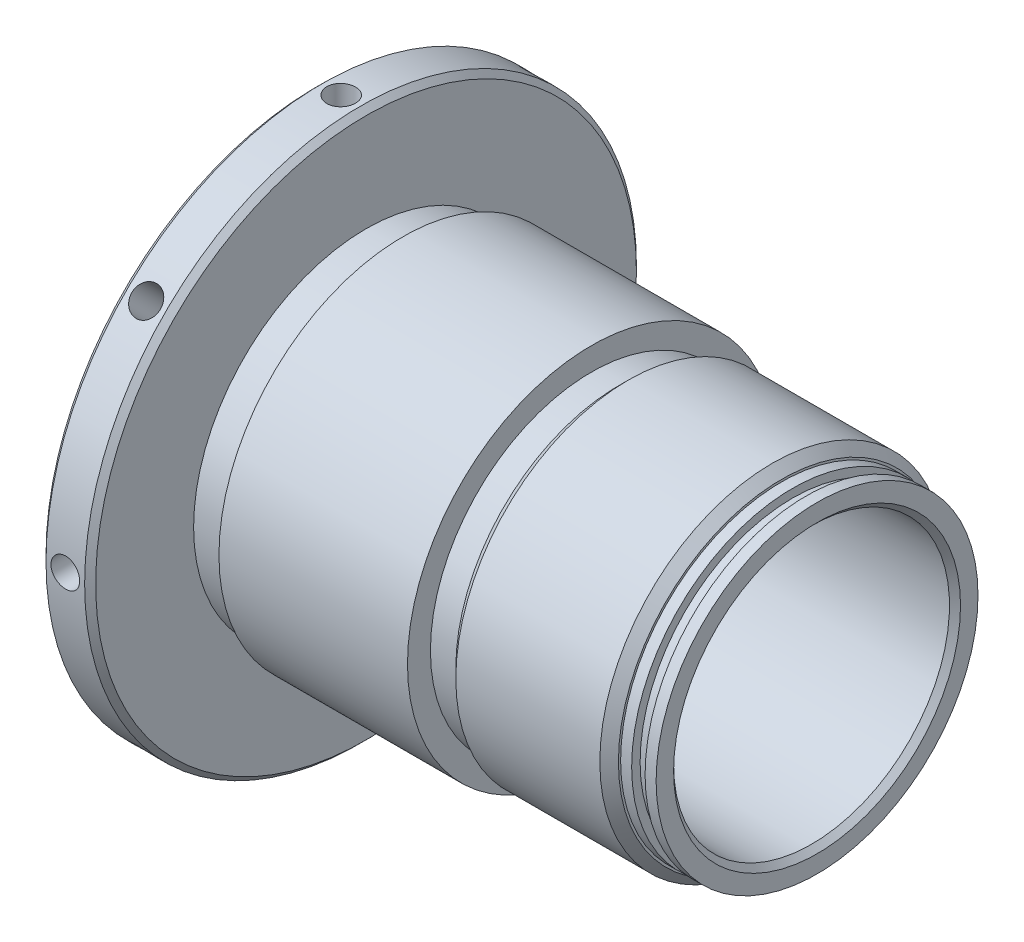
from build123d import *

# Parameters (mm, degrees)
CHAMFER1_SIZE      = 0.762
SKETCH3_W          = 6.858
SKETCH3_H          = 18.542
SKETCH5_W          = 5.08
SKETCH5_H          = 1.58115
CHAMFER3_SIZE      = 0.762
SKETCH6_R          = 1.9812
CUT_EXTRUDE2_DEPTH = 6.35
CHAMFER4_SIZE      = 1.2827
CIRPATTERN2_COUNT  = 8
SKETCH7_W          = 1.524
SKETCH7_H          = 0.4064
EXTRUDE1_DEPTH     = 0.0254


with BuildPart() as part:
    # Sketch1 → Revolve1 (revolve)
    with BuildSketch(Plane.XY, mode=Mode.PRIVATE) as revolve1_sk:
        Polygon((0, 19.558), (0, 25.39365), (62.2808, 25.39365), (62.2808, 19.05), (22.098, 19.05), (20.828, 20.32), (17.78, 20.32), (17.018, 19.558), align=None)
    revolve(revolve1_sk.sketch.rotate(Axis((0, 0, 0), (1, 0, 0)), 90), axis=Axis((0, 0, 0), (1, 0, 0)))  # turned: the seam where the file's is

    # Sketch2 → Cut-Revolve1 (revolve, cut)
    with BuildSketch(Plane.XY, mode=Mode.PRIVATE) as cut_revolve1_sk:
        Polygon((31.115, 25.39365), (62.2808, 25.39365), (62.2808, 22.225), (60.7568, 22.225), (60.7568, 21.0566), (58.9026, 21.0566), (58.9026, 22.225), (57.3786, 22.225), (57.3786, 23.8125), (34.925, 23.8125), (34.925, 22.225), (31.115, 22.225), align=None)
    revolve(cut_revolve1_sk.sketch.rotate(Axis((0, 0, 0), (1, 0, 0)), 90), axis=Axis((0, 0, 0), (1, 0, 0)), mode=Mode.SUBTRACT)  # turned: the seam where the file's is

    # Chamfer1
    chamfer1_edges = [part.edges().sort_by_distance(p)[0] for p in [
        (62.2808, 0, -19.05),
    ]]
    chamfer(chamfer1_edges, length=CHAMFER1_SIZE)

    # Sketch3 → Revolve2 (revolve)
    with BuildSketch(Plane.XY, mode=Mode.PRIVATE) as revolve2_sk:
        with Locations((-3.429, 28.829)):
            Rectangle(SKETCH3_W, SKETCH3_H)
    revolve(revolve2_sk.sketch.rotate(Axis((0, 0, 0), (-1, 0, 0)), 270), axis=Axis((0, 0, 0), (-1, 0, 0)))  # turned: the seam where the file's is

    # Sketch5 → Cut-Revolve2 (revolve, cut)
    with BuildSketch(Plane.XY, mode=Mode.PRIVATE) as cut_revolve2_sk:
        with Locations((2.54, 24.603075)):
            Rectangle(SKETCH5_W, SKETCH5_H)
    revolve(cut_revolve2_sk.sketch.rotate(Axis((23.353313309, 0, 0), (1, 0, 0)), 90), axis=Axis((23.353313309, 0, 0), (1, 0, 0)), mode=Mode.SUBTRACT)  # turned: the seam where the file's is

    # Chamfer3
    chamfer3_edges = [part.edges().sort_by_distance(p)[0] for p in [
        (0, 0, -38.1),
        (-6.858, 0, -38.1),
    ]]
    chamfer(chamfer3_edges, length=CHAMFER3_SIZE)

    # Sketch6 → Cut-Extrude2 (cut)
    with BuildSketch(Plane(origin=(-3.429, 38.1, 0), x_dir=(0, 0, 1), z_dir=(0, 1, 0))):
        Circle(SKETCH6_R)
    cut_extrude2 = extrude(amount=-CUT_EXTRUDE2_DEPTH, mode=Mode.SUBTRACT)

    # Chamfer4
    chamfer4_edges = [part.edges().sort_by_distance(p)[0] for p in [
        (34.925, 0, -23.8125),
        (57.3786, 0, -23.8125),
    ]]
    chamfer(chamfer4_edges, length=CHAMFER4_SIZE)

    # CirPattern2: Cut-Extrude2 ×8 about axis
    cirpattern2_axis = Axis((0, 0, 0), (1, 0, 0))
    for i in range(1, CIRPATTERN2_COUNT):
        add(cut_extrude2.rotate(cirpattern2_axis, i * 360 / CIRPATTERN2_COUNT), mode=Mode.SUBTRACT)

    # Sketch7 → Extrude1 (cut)
    with BuildSketch(Plane.ZY.offset(6.858)):
        with BuildLine():
            Line((-9.4996, 27.070692568), (-9.1646375, 27.271511318))
            add(Edge.make_bspline(
                [(-9.1646375, 27.271511318), (-9.13348371, 27.21936117), (-9.073794252, 27.119443498), (-8.974223262, 26.984429767), (-8.871050391, 26.869676221), (-8.76351161, 26.77585043), (-8.652263326, 26.701981233), (-8.536579299, 26.649675027), (-8.416849371, 26.617052049), (-8.335366779, 26.613089551), (-8.2946875, 26.611111318)],
                knots=[0, 0, 0, 0, 1.272034388, 2.437168799, 3.508375237, 4.49857839, 5.41946034, 6.295179144, 7.148887113, 8, 8, 8, 8], degree=3))
            add(Edge.make_bspline(
                [(-8.2946875, 26.611111318), (-8.259946467, 26.612078905), (-8.191072287, 26.613997148), (-8.089677592, 26.632428877), (-7.991204251, 26.660745465), (-7.897681832, 26.701298854), (-7.810400786, 26.750362973), (-7.73386228, 26.809624828), (-7.667694601, 26.875973751), (-7.613569219, 26.949994388), (-7.572043227, 27.029601436), (-7.540126584, 27.111312862), (-7.522414572, 27.196412272), (-7.519746458, 27.2537091), (-7.5184, 27.282623818)],
                knots=[0, 0, 0, 0, 1.095163259, 2.171163733, 3.241058638, 4.321873601, 5.38011039, 6.391990106, 7.366004449, 8.327778327, 9.272591725, 10.192022065, 11.087607919, 12, 12, 12, 12], degree=3))
            add(Edge.make_bspline(
                [(-7.5184, 27.282623818), (-7.520069088, 27.31561459), (-7.523462101, 27.382680009), (-7.552140231, 27.481626405), (-7.597254133, 27.579545879), (-7.638873647, 27.640115426), (-7.66048125, 27.671561318)],
                knots=[0, 0, 0, 0, 0.938893495, 1.908633276, 2.914225137, 4, 4, 4, 4], degree=3))
            add(Edge.make_bspline(
                [(-7.66048125, 27.671561318), (-7.678222176, 27.694256613), (-7.715467032, 27.741902547), (-7.7794966, 27.812824113), (-7.854630626, 27.885979548), (-7.938297896, 27.964162293), (-8.033546168, 28.043736112), (-8.137392197, 28.128495559), (-8.252487304, 28.215217299), (-8.333206483, 28.273376914), (-8.37485625, 28.303386318)],
                knots=[0, 0, 0, 0, 0.722233717, 1.516239348, 2.393582979, 3.351407094, 4.387010283, 5.505090956, 6.712668013, 8, 8, 8, 8], degree=3))
            add(Edge.make_bspline(
                [(-8.37485625, 28.303386318), (-8.416545222, 28.333080077), (-8.496251362, 28.389852282), (-8.60771773, 28.474109077), (-8.707394124, 28.551142514), (-8.794837518, 28.621677776), (-8.87000945, 28.68572443), (-8.933502281, 28.742667446), (-8.983698595, 28.794046823), (-9.01161153, 28.827377787), (-9.02414375, 28.842342568)],
                knots=[0, 0, 0, 0, 1.452282411, 2.77665338, 3.964542531, 5.026858415, 5.96415736, 6.766646006, 7.446254459, 8, 8, 8, 8], degree=3))
            add(Edge.make_bspline(
                [(-9.02414375, 28.842342568), (-9.041660439, 28.865665296), (-9.07610936, 28.911532571), (-9.121581869, 28.983223547), (-9.160231303, 29.056610892), (-9.190529321, 29.13189181), (-9.216042897, 29.208009434), (-9.233203406, 29.285956913), (-9.243948753, 29.365384487), (-9.245049152, 29.418835565), (-9.2456, 29.445592568)],
                knots=[0, 0, 0, 0, 1.068054152, 2.10047183, 3.106115577, 4.101338837, 5.06977816, 6.043150881, 7.020423561, 8, 8, 8, 8], degree=3))
            add(Edge.make_bspline(
                [(-9.2456, 29.445592568), (-9.244122354, 29.487514505), (-9.241198646, 29.570462326), (-9.216472685, 29.691633459), (-9.177445429, 29.807320161), (-9.122770097, 29.916377108), (-9.052287658, 30.015964652), (-8.970723382, 30.107228332), (-8.873574972, 30.183950112), (-8.766983442, 30.250984929), (-8.650311851, 30.303453813), (-8.528053807, 30.343033639), (-8.400014996, 30.365459982), (-8.313291493, 30.368678317), (-8.2692875, 30.370311318)],
                knots=[0, 0, 0, 0, 1.005424448, 1.989358655, 2.955360095, 3.929531133, 4.905563448, 5.876582895, 6.856512386, 7.866279853, 8.892233794, 9.918561126, 10.94386622, 12, 12, 12, 12], degree=3))
            add(Edge.make_bspline(
                [(-8.2692875, 30.370311318), (-8.222594465, 30.368700827), (-8.129736921, 30.365498075), (-7.99314822, 30.337650858), (-7.861641014, 30.291573046), (-7.755852559, 30.239282206), (-7.673057915, 30.187056172), (-7.609916807, 30.139484928), (-7.545932594, 30.084718777), (-7.48058916, 30.022611841), (-7.414993711, 29.95259425), (-7.348172418, 29.875145532), (-7.27996902, 29.79073899), (-7.236092958, 29.730482772), (-7.2136, 29.699592568)],
                knots=[0, 0, 0, 0, 1.286793592, 2.559021753, 3.825965368, 5.121522368, 5.803751409, 6.523245864, 7.299691795, 8.125521123, 9.008227632, 9.944561021, 10.946284179, 12, 12, 12, 12], degree=3))
            Line((-7.2136, 29.699592568), (-7.53506875, 29.455911318))
            add(Edge.make_bspline(
                [(-7.53506875, 29.455911318), (-7.554479905, 29.48091824), (-7.591861251, 29.529075725), (-7.64861356, 29.596517262), (-7.702104429, 29.658122936), (-7.754804801, 29.711632463), (-7.803931352, 29.759976158), (-7.851612657, 29.801365981), (-7.897162541, 29.836207472), (-7.95457988, 29.873390136), (-8.026715619, 29.910247818), (-8.117267255, 29.941436523), (-8.211896471, 29.960178745), (-8.27634732, 29.962656816), (-8.308975, 29.963911318)],
                knots=[0, 0, 0, 0, 1.181633172, 2.275549214, 3.290209073, 4.226197932, 5.078386478, 5.862611352, 6.581680152, 7.217281963, 8.414376989, 9.595101626, 10.782541182, 12, 12, 12, 12], degree=3))
            add(Edge.make_bspline(
                [(-8.308975, 29.963911318), (-8.349908316, 29.962539535), (-8.428844359, 29.959894181), (-8.540912619, 29.931002641), (-8.641777124, 29.885512183), (-8.728443377, 29.821757192), (-8.800600919, 29.746221403), (-8.852797568, 29.659298964), (-8.884213925, 29.563315595), (-8.888047581, 29.496360481), (-8.89, 29.462261318)],
                knots=[0, 0, 0, 0, 1.14458467, 2.207223713, 3.21896685, 4.227309161, 5.202851033, 6.127160689, 7.046193047, 8, 8, 8, 8], degree=3))
            add(Edge.make_bspline(
                [(-8.89, 29.462261318), (-8.889554936, 29.441032501), (-8.888664079, 29.398540155), (-8.876239354, 29.335762808), (-8.860277302, 29.27314405), (-8.83498289, 29.210965409), (-8.800062481, 29.148139453), (-8.754205993, 29.083584329), (-8.696453093, 29.016731046), (-8.652213449, 28.97324951), (-8.62885625, 28.950292568)],
                knots=[0, 0, 0, 0, 0.858281714, 1.717966888, 2.583508476, 3.4729293, 4.427298488, 5.488583878, 6.674047936, 8, 8, 8, 8], degree=3))
            add(Edge.make_bspline(
                [(-8.62885625, 28.950292568), (-8.620182701, 28.942552273), (-8.599576333, 28.924163105), (-8.561904183, 28.894057604), (-8.512155913, 28.856921117), (-8.451630591, 28.810971637), (-8.379212227, 28.757670041), (-8.294892858, 28.697697858), (-8.199612384, 28.629108194), (-8.13200035, 28.581154617), (-8.09625, 28.555798818)],
                knots=[0, 0, 0, 0, 0.420754252, 0.999615792, 1.744751191, 2.668019286, 3.750313428, 4.999500688, 6.413464383, 8, 8, 8, 8], degree=3))
            add(Edge.make_bspline(
                [(-8.09625, 28.555798818), (-8.053245605, 28.52450564), (-7.969973554, 28.463910738), (-7.851489213, 28.372870998), (-7.744058577, 28.283832735), (-7.647304463, 28.197364555), (-7.560271017, 28.114122351), (-7.48392381, 28.033104652), (-7.417484913, 27.954891888), (-7.345958817, 27.85461761), (-7.272871987, 27.731464991), (-7.210105865, 27.580578793), (-7.17052902, 27.429106067), (-7.165353542, 27.327298611), (-7.1628, 27.277067568)],
                knots=[0, 0, 0, 0, 1.163667725, 2.253281268, 3.268753668, 4.215851969, 5.092017293, 5.902905408, 6.650798638, 7.335211899, 8.59617414, 9.77448103, 10.901945474, 12, 12, 12, 12], degree=3))
            add(Edge.make_bspline(
                [(-7.1628, 27.277067568), (-7.163543955, 27.241543673), (-7.165017419, 27.171185732), (-7.181954883, 27.067874556), (-7.20677045, 26.967534282), (-7.244172374, 26.871405199), (-7.289822798, 26.777728671), (-7.347748838, 26.688961967), (-7.414891915, 26.60314046), (-7.491913912, 26.522552612), (-7.576195182, 26.44857325), (-7.665274116, 26.382764509), (-7.759296517, 26.327892828), (-7.857752326, 26.283116755), (-7.96066416, 26.248096478), (-8.067997407, 26.222722548), (-8.179928993, 26.207149512), (-8.256007618, 26.205533122), (-8.2946875, 26.204711318)],
                knots=[0, 0, 0, 0, 0.983748083, 1.948392443, 2.894712957, 3.844097841, 4.80183111, 5.778335162, 6.776009319, 7.81870978, 8.863265674, 9.881300176, 10.883814829, 11.87499822, 12.874611388, 13.892143829, 14.928324115, 16, 16, 16, 16], degree=3))
            add(Edge.make_bspline(
                [(-8.2946875, 26.204711318), (-8.324615329, 26.205290034), (-8.384094078, 26.206440178), (-8.472070093, 26.216608014), (-8.558268809, 26.230993907), (-8.64160859, 26.25383326), (-8.723163172, 26.281543995), (-8.802577859, 26.315664032), (-8.879891136, 26.356552832), (-8.955536277, 26.403303519), (-9.029320891, 26.457710378), (-9.100552919, 26.521078773), (-9.171569526, 26.59166101), (-9.240274595, 26.671373815), (-9.308057837, 26.758929363), (-9.373582811, 26.855146832), (-9.438205839, 26.959502131), (-9.478753042, 27.032936821), (-9.4996, 27.070692568)],
                knots=[0, 0, 0, 0, 0.915332311, 1.819136955, 2.706846663, 3.586547465, 4.459518054, 5.340707479, 6.227863349, 7.133153174, 8.059268498, 9.028702269, 10.047606654, 11.120612155, 12.245963614, 13.433783089, 14.680604001, 16, 16, 16, 16], degree=3))
        make_face()
        Polygon((-6.8072, 29.862311318), (-6.8072, 30.268711318), (-4.7244, 30.268711318), (-4.7244, 29.862311318), (-5.588, 29.862311318), (-5.588, 26.306311318), (-5.9436, 26.306311318), (-5.9436, 29.862311318), align=None)
        with BuildLine():
            Line((-0.4064, 29.592436318), (-0.7112, 29.303511318))
            add(Edge.make_bspline(
                [(-0.7112, 29.303511318), (-0.766355349, 29.355397093), (-0.875350837, 29.457931396), (-1.05304777, 29.590967273), (-1.238446919, 29.704932803), (-1.430580862, 29.797660023), (-1.62469154, 29.871646817), (-1.818202449, 29.924321989), (-2.009128657, 29.957914693), (-2.136114767, 29.961931852), (-2.1986875, 29.963911318)],
                knots=[0, 0, 0, 0, 1.08915593, 2.152340314, 3.188132944, 4.216796309, 5.218260357, 6.173443236, 7.099959455, 8, 8, 8, 8], degree=3))
            add(Edge.make_bspline(
                [(-2.1986875, 29.963911318), (-2.237082816, 29.963443069), (-2.313773869, 29.962507785), (-2.427689409, 29.950570528), (-2.540410221, 29.933402169), (-2.651723519, 29.908561456), (-2.761845731, 29.877078422), (-2.870393859, 29.837697302), (-2.977570388, 29.791784131), (-3.082365771, 29.738730455), (-3.183962277, 29.680449386), (-3.279916701, 29.615863918), (-3.370840648, 29.54704406), (-3.455025147, 29.472266803), (-3.532954446, 29.392209494), (-3.606483425, 29.308361367), (-3.673026042, 29.218431621), (-3.733131308, 29.124074847), (-3.786750073, 29.026948284), (-3.834082247, 28.92798679), (-3.873816162, 28.827518604), (-3.905254359, 28.725417658), (-3.931191837, 28.622473838), (-3.94943881, 28.517974345), (-3.959726018, 28.411807288), (-3.961505453, 28.340713614), (-3.9624, 28.304973818)],
                knots=[0, 0, 0, 0, 1.02818874, 2.053710826, 3.065248034, 4.081641283, 5.106893873, 6.131558223, 7.173050175, 8.228653731, 9.27666206, 10.308777013, 11.325269123, 12.329503258, 13.32196095, 14.316845687, 15.314881793, 16.315733098, 17.311955233, 18.285320748, 19.252783886, 20.203351036, 21.145449891, 22.095197417, 23.042428769, 24, 24, 24, 24], degree=3))
            add(Edge.make_bspline(
                [(-3.9624, 28.304973818), (-3.961544441, 28.268439565), (-3.959835658, 28.195470821), (-3.948899072, 28.086568138), (-3.928602255, 27.979282872), (-3.901468069, 27.873262482), (-3.86752636, 27.768325397), (-3.825216231, 27.664926557), (-3.775102512, 27.563069792), (-3.717096879, 27.463672856), (-3.653487676, 27.366851019), (-3.582228915, 27.275648434), (-3.506535093, 27.188850616), (-3.423648591, 27.108384728), (-3.336227244, 27.032098457), (-3.241659161, 26.962093579), (-3.141803896, 26.897021661), (-3.036509102, 26.837702813), (-2.926917289, 26.784710201), (-2.814547301, 26.737587194), (-2.699040154, 26.698779066), (-2.581002873, 26.66714994), (-2.460576173, 26.641224186), (-2.337148768, 26.624545335), (-2.211628191, 26.612442092), (-2.127015518, 26.611557152), (-2.0843875, 26.611111318)],
                knots=[0, 0, 0, 0, 0.93586088, 1.869166235, 2.799637598, 3.729985548, 4.670839027, 5.622275134, 6.589130586, 7.576015415, 8.568469353, 9.55398029, 10.53834874, 11.515998671, 12.510579167, 13.508179873, 14.527009472, 15.561807829, 16.601455013, 17.643573243, 18.680854198, 19.719860599, 20.772568776, 21.833555941, 22.908541556, 24, 24, 24, 24], degree=3))
            add(Edge.make_bspline(
                [(-2.0843875, 26.611111318), (-2.033014025, 26.612185215), (-1.93213386, 26.614293986), (-1.783842237, 26.63070997), (-1.641418783, 26.656348729), (-1.505263696, 26.693896315), (-1.375218837, 26.741788909), (-1.250807468, 26.799521515), (-1.133009099, 26.869308503), (-1.021469607, 26.948074071), (-0.918722101, 27.035829721), (-0.826053877, 27.130524803), (-0.744942996, 27.231699668), (-0.674180533, 27.338758413), (-0.615640426, 27.452587189), (-0.567590332, 27.572628167), (-0.530758928, 27.698935342), (-0.51563957, 27.786211879), (-0.508, 27.830311318)],
                knots=[0, 0, 0, 0, 1.13008108, 2.219097802, 3.278683437, 4.311054135, 5.322181354, 6.324827112, 7.324222904, 8.330512327, 9.32562643, 10.293043162, 11.24128371, 12.174520618, 13.111833804, 14.052305215, 15.015860969, 16, 16, 16, 16], degree=3))
            Line((-0.508, 27.830311318), (-1.8288, 27.830311318))
            Line((-1.8288, 27.830311318), (-1.8288, 28.236711318))
            Line((-1.8288, 28.236711318), (-0.1524, 28.236711318))
            add(Edge.make_bspline(
                [(-0.1524, 28.236711318), (-0.154331215, 28.160964394), (-0.158110953, 28.012713981), (-0.184623842, 27.796513809), (-0.227436455, 27.592312439), (-0.285921832, 27.399894817), (-0.361632293, 27.219533623), (-0.453755294, 27.051045734), (-0.563765241, 26.895519631), (-0.687743576, 26.751685639), (-0.826880374, 26.623384019), (-0.977416048, 26.510618713), (-1.139599309, 26.415631364), (-1.313276743, 26.338352493), (-1.497879789, 26.278040242), (-1.693835617, 26.235278501), (-1.90087849, 26.209658796), (-2.042773932, 26.206385424), (-2.11534375, 26.204711318)],
                knots=[0, 0, 0, 0, 1.140356446, 2.231883559, 3.274166699, 4.278491846, 5.25512956, 6.21435461, 7.1637429, 8.11826594, 9.068280886, 10.0076534, 10.945064095, 11.891975133, 12.864533718, 13.863980011, 14.907571808, 16, 16, 16, 16], degree=3))
            add(Edge.make_bspline(
                [(-2.11534375, 26.204711318), (-2.160073739, 26.205355628), (-2.248295693, 26.206626416), (-2.378591776, 26.215657685), (-2.505295313, 26.229560701), (-2.628387846, 26.2505559), (-2.748322156, 26.276271484), (-2.864499254, 26.309200974), (-2.9773617, 26.34731779), (-3.087083936, 26.390672869), (-3.192670061, 26.440906655), (-3.294590367, 26.496730802), (-3.393408237, 26.557857458), (-3.48845055, 26.625343748), (-3.580212513, 26.698684896), (-3.668102444, 26.778027902), (-3.752612373, 26.863130201), (-3.805550562, 26.92356134), (-3.832225, 26.954011318)],
                knots=[0, 0, 0, 0, 1.107784379, 2.184907829, 3.233506516, 4.263428166, 5.276301166, 6.270063455, 7.25232949, 8.225834625, 9.190232166, 10.146266622, 11.1027726, 12.066435141, 13.031522626, 14.010570082, 14.99756817, 16, 16, 16, 16], degree=3))
            add(Edge.make_bspline(
                [(-3.832225, 26.954011318), (-3.870927382, 27.002319374), (-3.947689726, 27.098133622), (-4.046498574, 27.251648256), (-4.130729465, 27.410599208), (-4.199072739, 27.575428966), (-4.25243844, 27.745983356), (-4.290710982, 27.922044439), (-4.313135097, 28.103838933), (-4.316365627, 28.226860432), (-4.318, 28.289098818)],
                knots=[0, 0, 0, 0, 1.023165419, 2.029347347, 3.013907458, 3.994755782, 4.975994455, 5.96558838, 6.970761222, 8, 8, 8, 8], degree=3))
            add(Edge.make_bspline(
                [(-4.318, 28.289098818), (-4.317397446, 28.335703721), (-4.316199995, 28.428321206), (-4.301680045, 28.565824759), (-4.280847537, 28.700886777), (-4.25022718, 28.833396856), (-4.211626311, 28.963443494), (-4.163450902, 29.091087074), (-4.107360417, 29.216402923), (-4.042167055, 29.33852847), (-3.969616123, 29.455843148), (-3.890877325, 29.567874691), (-3.804832563, 29.672582883), (-3.712886996, 29.771293794), (-3.613943615, 29.862767323), (-3.508929346, 29.947850365), (-3.39776326, 30.026657051), (-3.280095626, 30.0979461), (-3.15768273, 30.161982583), (-3.030818001, 30.218123238), (-2.899540167, 30.264521035), (-2.764832744, 30.303888928), (-2.625676086, 30.333001406), (-2.483080023, 30.354113917), (-2.336301279, 30.368560374), (-2.237087278, 30.369722213), (-2.18678125, 30.370311318)],
                knots=[0, 0, 0, 0, 1.008945113, 2.00506715, 2.99143336, 3.967273523, 4.948097931, 5.927297278, 6.919902385, 7.919676788, 8.923139349, 9.905703106, 10.883022732, 11.856032218, 12.825136022, 13.798837087, 14.781400844, 15.773989409, 16.776158564, 17.77167057, 18.775803737, 19.789618931, 20.80898985, 21.851988756, 22.910860228, 24, 24, 24, 24], degree=3))
            add(Edge.make_bspline(
                [(-2.18678125, 30.370311318), (-2.145755417, 30.369655267), (-2.06440601, 30.368354395), (-1.943353861, 30.359337504), (-1.824172777, 30.345045827), (-1.706686044, 30.325543136), (-1.591293749, 30.298979557), (-1.477667168, 30.26719173), (-1.365641588, 30.23018085), (-1.255568098, 30.18604102), (-1.146706574, 30.13594086), (-1.038451722, 30.079546372), (-0.931173426, 30.015893241), (-0.824685645, 29.944792462), (-0.718316876, 29.867465187), (-0.613749545, 29.781699804), (-0.508459583, 29.690878476), (-0.440757095, 29.625575652), (-0.4064, 29.592436318)],
                knots=[0, 0, 0, 0, 0.985871117, 1.954866573, 2.915460327, 3.869826059, 4.81536089, 5.759505086, 6.70452669, 7.649098992, 8.607881297, 9.583363685, 10.581137262, 11.603961102, 12.659522466, 13.73993555, 14.853081303, 16, 16, 16, 16], degree=3))
        make_face()
        with BuildLine():
            add(Edge.make_bspline(
                [(1.8288, 28.285923818), (1.829171354, 28.349432472), (1.829892715, 28.472798948), (1.837917617, 28.65256131), (1.85124865, 28.821201381), (1.869518001, 28.978727234), (1.891750439, 29.125179535), (1.921429366, 29.260166907), (1.955180865, 29.384314114), (1.994298183, 29.498025992), (2.038436816, 29.602834532), (2.086477249, 29.700677738), (2.140326032, 29.791407564), (2.196905609, 29.87647213), (2.258506293, 29.954478987), (2.323375072, 30.026529755), (2.39404377, 30.090959228), (2.468110092, 30.149655168), (2.546244617, 30.201109164), (2.626220189, 30.246430799), (2.708587283, 30.285148957), (2.793570781, 30.315592004), (2.880406843, 30.340737221), (2.969399026, 30.357932846), (3.060694266, 30.368752358), (3.122316871, 30.369786735), (3.15356875, 30.370311318)],
                knots=[0, 0, 0, 0, 1.646270934, 3.197905019, 4.663502075, 6.030701355, 7.308322542, 8.50163776, 9.611534131, 10.641858119, 11.616356847, 12.558055219, 13.465016945, 14.349605745, 15.204443733, 16.039544428, 16.859896111, 17.680448484, 18.487036065, 19.28249412, 20.06191084, 20.843045899, 21.620316918, 22.403196591, 23.190181807, 24, 24, 24, 24], degree=3))
            add(Edge.make_bspline(
                [(3.15356875, 30.370311318), (3.185081693, 30.369759056), (3.247751021, 30.368660779), (3.340403679, 30.358105011), (3.430915856, 30.340589931), (3.518901671, 30.315772883), (3.605083856, 30.284984269), (3.688788319, 30.246393756), (3.770534988, 30.201472744), (3.849024797, 30.148689186), (3.925119423, 30.089839309), (3.996949768, 30.023313252), (4.064522371, 29.949782747), (4.128685294, 29.870034506), (4.187618179, 29.782538958), (4.24374097, 29.688817884), (4.293975186, 29.587232291), (4.342355722, 29.479477123), (4.384116006, 29.36257086), (4.421777198, 29.237172492), (4.452207262, 29.101800847), (4.477554477, 28.957166177), (4.497190882, 28.802737316), (4.511492476, 28.638845302), (4.519047171, 28.465382309), (4.520469901, 28.346784452), (4.5212, 28.285923818)],
                knots=[0, 0, 0, 0, 0.810914788, 1.612654377, 2.396697861, 3.181598691, 3.963628158, 4.749916497, 5.551656086, 6.361998678, 7.18212741, 8.025565596, 8.878627764, 9.750805457, 10.657531673, 11.591944965, 12.560506719, 13.57287815, 14.630710178, 15.753379473, 16.941251878, 18.199788006, 19.531962791, 20.947069417, 22.433333509, 24, 24, 24, 24], degree=3))
            add(Edge.make_bspline(
                [(4.5212, 28.285923818), (4.520462332, 28.225328637), (4.519025015, 28.107261399), (4.511577168, 27.934578902), (4.496906516, 27.77155666), (4.478554957, 27.617803696), (4.453137901, 27.47395995), (4.421885698, 27.339527664), (4.387186029, 27.213926295), (4.344352719, 27.098184805), (4.297471062, 26.990688603), (4.246463431, 26.890307258), (4.191816471, 26.79615351), (4.132280001, 26.708980996), (4.068821132, 26.628172199), (4.000081655, 26.555153519), (3.927999276, 26.488165556), (3.851680717, 26.428557896), (3.771966794, 26.37638463), (3.690500895, 26.329725842), (3.605837559, 26.292102633), (3.519895421, 26.259797705), (3.431445181, 26.235117102), (3.340597096, 26.218051775), (3.24781327, 26.206083234), (3.185092367, 26.205170207), (3.15356875, 26.204711318)],
                knots=[0, 0, 0, 0, 1.561518951, 3.042555995, 4.452378317, 5.7783523, 7.031515105, 8.214008947, 9.334062868, 10.386615937, 11.391082383, 12.354592575, 13.286541444, 14.194233754, 15.072674879, 15.931287219, 16.775624067, 17.606195743, 18.42308326, 19.229000347, 20.022332153, 20.807536673, 21.593273796, 22.3848459, 23.188221202, 24, 24, 24, 24], degree=3))
            add(Edge.make_bspline(
                [(3.15356875, 26.204711318), (3.122317738, 26.205239286), (3.060696843, 26.206280335), (2.96938908, 26.217050966), (2.880764407, 26.234367224), (2.794385498, 26.258613267), (2.709809185, 26.288291458), (2.628187949, 26.326957331), (2.548614258, 26.371487993), (2.471300412, 26.422201529), (2.397699216, 26.48030354), (2.327396497, 26.544567202), (2.26215839, 26.616596175), (2.201438464, 26.695253124), (2.143729971, 26.779814411), (2.090645841, 26.871434578), (2.041545078, 26.969750338), (1.996664116, 27.075396878), (1.956871812, 27.189915817), (1.921722258, 27.314617275), (1.89396943, 27.450601903), (1.870214326, 27.596777519), (1.851053991, 27.753772256), (1.837973174, 27.921671346), (1.829888389, 28.100370162), (1.829169417, 28.222943921), (1.8288, 28.285923818)],
                knots=[0, 0, 0, 0, 0.810891512, 1.598919785, 2.382837074, 3.152667961, 3.926044502, 4.706494248, 5.493654104, 6.291793342, 7.103789334, 7.925228297, 8.761435821, 9.622817696, 10.50288917, 11.416980706, 12.369136599, 13.353924996, 14.394355917, 15.514179734, 16.714354668, 17.994756427, 19.357759367, 20.818452758, 22.365282078, 24, 24, 24, 24], degree=3))
        make_face()
        with BuildLine():
            add(Edge.make_bspline(
                [(2.1844, 28.287511318), (2.184535228, 28.234586448), (2.184797678, 28.131869668), (2.191653989, 27.982608029), (2.200994195, 27.843391563), (2.213041359, 27.714043502), (2.230932103, 27.595001671), (2.250978211, 27.48544733), (2.275373111, 27.385960255), (2.304236385, 27.295857758), (2.337111961, 27.213610709), (2.373006622, 27.137078408), (2.411567253, 27.065356776), (2.454722488, 26.999090041), (2.501722284, 26.938062103), (2.551505039, 26.881192796), (2.605928699, 26.830477493), (2.681218536, 26.769652553), (2.780614179, 26.706798549), (2.905849176, 26.65206525), (3.034534853, 26.617668837), (3.121878886, 26.613294624), (3.165475, 26.611111318)],
                knots=[0, 0, 0, 0, 1.459021318, 2.831673884, 4.118529203, 5.306027144, 6.411944654, 7.436330062, 8.375795394, 9.233974572, 10.042671642, 10.816086306, 11.563610507, 12.285937304, 12.993564865, 13.685989202, 14.367179055, 15.041617293, 16.353048772, 17.594441528, 18.799311195, 20, 20, 20, 20], degree=3))
            add(Edge.make_bspline(
                [(3.165475, 26.611111318), (3.209353114, 26.612920189), (3.297018749, 26.616534195), (3.425099135, 26.651401885), (3.549439553, 26.704010715), (3.646882826, 26.766217571), (3.721016549, 26.82545922), (3.774131944, 26.875968101), (3.822883104, 26.932523852), (3.869121, 26.993544015), (3.911528955, 27.060194395), (3.95009232, 27.132154495), (3.985282222, 27.209624144), (4.005330886, 27.263704949), (4.01558125, 27.291355068)],
                knots=[0, 0, 0, 0, 1.353760809, 2.704726607, 4.075137775, 5.516104923, 6.260822281, 7.007110065, 7.778089737, 8.566572457, 9.372053459, 10.217411131, 11.088608312, 12, 12, 12, 12], degree=3))
            add(Edge.make_bspline(
                [(4.01558125, 27.291355068), (4.027527057, 27.326710702), (4.051782168, 27.398497802), (4.083041853, 27.509856698), (4.10766013, 27.626694021), (4.129808095, 27.748311531), (4.144925281, 27.875606122), (4.157093034, 28.008183933), (4.164260095, 28.146144922), (4.165148523, 28.239878314), (4.1656, 28.287511318)],
                knots=[0, 0, 0, 0, 0.884706709, 1.796334032, 2.740027952, 3.714592787, 4.726048262, 5.777819803, 6.87074269, 8, 8, 8, 8], degree=3))
            add(Edge.make_bspline(
                [(4.1656, 28.287511318), (4.164977123, 28.335136618), (4.163758642, 28.428301885), (4.159101138, 28.564742239), (4.147074037, 28.694332827), (4.133716086, 28.817631929), (4.114020444, 28.933957014), (4.092784463, 29.044281897), (4.06425381, 29.147239795), (4.033777549, 29.244442654), (3.99889666, 29.334786115), (3.960500172, 29.418691391), (3.919493002, 29.49656356), (3.874953089, 29.568188969), (3.827409177, 29.63388844), (3.775606401, 29.692344702), (3.721599599, 29.745369502), (3.645954909, 29.805895241), (3.546924016, 29.86760871), (3.423698303, 29.924402083), (3.295462989, 29.957016363), (3.208773088, 29.961614657), (3.165475, 29.963911318)],
                knots=[0, 0, 0, 0, 1.31362396, 2.569729283, 3.763502607, 4.902122613, 5.988968491, 7.01645872, 7.998833611, 8.933434873, 9.825090667, 10.667526885, 11.477055099, 12.250526234, 12.991942729, 13.710640831, 14.402115721, 15.076753259, 16.378508321, 17.609869233, 18.806226677, 20, 20, 20, 20], degree=3))
            add(Edge.make_bspline(
                [(3.165475, 29.963911318), (3.121650186, 29.961611488), (3.033920719, 29.957007639), (2.904352554, 29.924523597), (2.780154691, 29.867903204), (2.681385673, 29.805690838), (2.605688225, 29.746437888), (2.552385235, 29.695055235), (2.502406723, 29.638850001), (2.456366238, 29.577260816), (2.413244817, 29.511071338), (2.373642313, 29.439760858), (2.337961093, 29.362968001), (2.305034075, 29.280757897), (2.276082756, 29.190663173), (2.252201979, 29.091298642), (2.230140408, 28.982092756), (2.214522587, 28.862406191), (2.200638614, 28.733025732), (2.191716027, 28.593461719), (2.184774743, 28.443949748), (2.184527416, 28.340701878), (2.1844, 28.287511318)],
                knots=[0, 0, 0, 0, 1.207732386, 2.417664972, 3.655092373, 4.956220595, 5.625982001, 6.301752483, 6.994047911, 7.697131622, 8.419323945, 9.170223765, 9.943494443, 10.752040957, 11.610060368, 12.549350801, 13.567764191, 14.679664412, 15.874934091, 17.154273443, 18.533957287, 20, 20, 20, 20], degree=3))
        make_face(mode=Mode.SUBTRACT)
        with Locations((5.6388, 27.830311318)):
            Rectangle(SKETCH7_W, SKETCH7_H)
        Polygon((7.54776875, 30.268711318), (8.2804, 30.268711318), (8.2804, 26.306311318), (7.9248, 26.306311318), (7.9248, 29.862311318), (7.3152, 29.862311318), align=None)
    extrude(amount=-EXTRUDE1_DEPTH, mode=Mode.SUBTRACT)


solid = part.part
